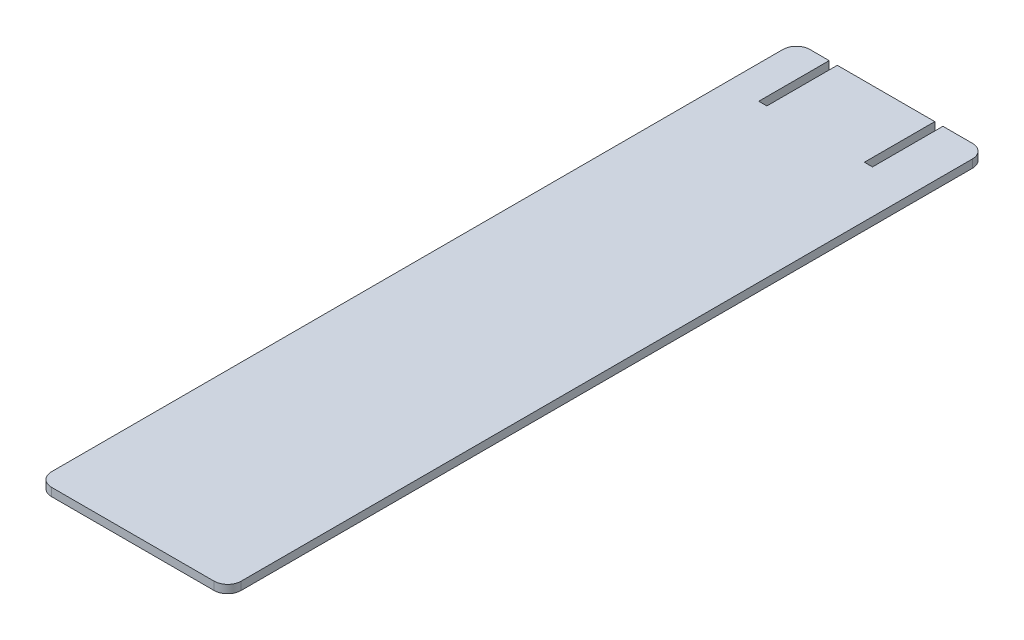
from build123d import *

# Parameters (mm, degrees)
BOSS_EXTRUDE1_DEPTH = 3
SKETCH2_W           = 3
SKETCH2_H           = 26
CUT_EXTRUDE1_DEPTH  = 4


with BuildPart() as part:
    # Sketch1 → Boss-Extrude1 (new body)
    with BuildSketch(Plane(origin=(0, 0, 0), x_dir=(1, 0, 0), z_dir=(0, 1, 0))):
        with BuildLine():
            Line((145.58070197, 100.48875), (205.58070197, 100.48875))
            ThreePointArc((205.58070197, 100.48875), (209.116235876, 99.024283906), (210.58070197, 95.48875))
            Line((210.58070197, 95.48875), (210.58070197, -174.51125))
            ThreePointArc((210.58070197, -174.51125), (209.116235876, -178.046783906), (205.58070197, -179.51125))
            Line((205.58070197, -179.51125), (145.58070197, -179.51125))
            ThreePointArc((145.58070197, -179.51125), (142.045168065, -178.046783906), (140.58070197, -174.51125))
            Line((140.58070197, -174.51125), (140.58070197, 95.48875))
            ThreePointArc((140.58070197, 95.48875), (142.045168065, 99.024283906), (145.58070197, 100.48875))
        make_face()
    extrude(amount=BOSS_EXTRUDE1_DEPTH)

    # Sketch2 → Cut-Extrude1 (cut, through all)
    with BuildSketch(Plane(origin=(0, 3, 0), x_dir=(1, 0, 0), z_dir=(0, 1, 0))):
        with Locations((154.188003651, 87.48875)):
            Rectangle(SKETCH2_W, SKETCH2_H)
        with Locations((193.188003651, 87.48875)):
            Rectangle(SKETCH2_W, SKETCH2_H)
    extrude(amount=-CUT_EXTRUDE1_DEPTH, mode=Mode.SUBTRACT)


solid = part.part
